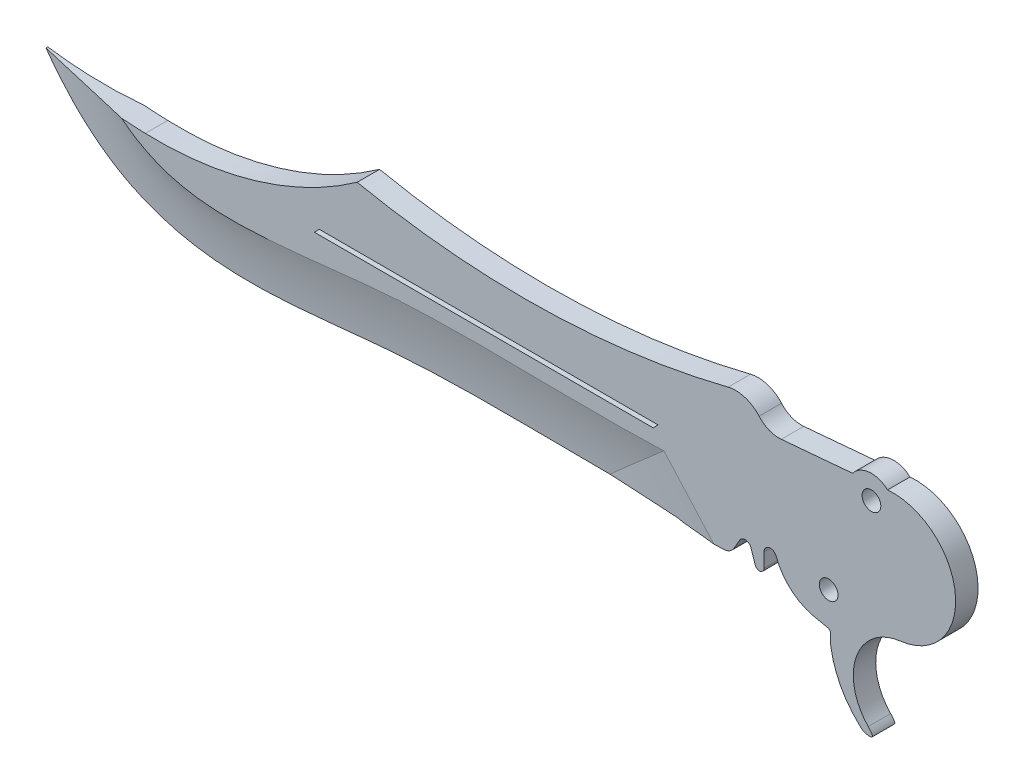
from build123d import *

# Parameters (mm, degrees)
SKETCH1_R           = 1.5
EXTRUDE1_DEPTH      = 1.8
SKETCH2_R           = 3.8
SKETCH2_R_2         = 1.5
EXTRUDE2_DEPTH      = 3.6
EXTRUDE4_DEPTH      = 1.0000001
EXTRUDE4_DEPTH_BACK = 4.6000001
EXTRUDE5_DEPTH      = 1.8
EXTRUDE6_DEPTH      = 15.6


with BuildPart() as part:
    # Sketch1 → Extrude1 (new body, symmetric)
    with BuildSketch(Plane.XY):
        with BuildLine():
            Line((0, 0), (85, -2.968265407))
            add(Edge.make_bspline(
                [(85, -2.968265407), (90.432696575, -3.157979352), (90.320000274, -9.186485994), (84.864174569, -11.468265407)],
                knots=[0, 0, 0, 0, 1, 1, 1, 1], degree=3))
            add(Edge.make_bspline(
                [(84.864174569, -11.468265407), (85.412432172, -11.551100755), (85.65372179, -11.5816869), (86.240355976, -11.568265407)],
                knots=[0, 0, 0, 0, 1, 1, 1, 1], degree=3))
            Line((86.240355976, -11.568265407), (92.79739008, -11.418248259))
            ThreePointArc((92.79739008, -11.418248259), (93.771255184, -11.13935102), (94.483539935, -10.419040433))
            Line((94.483539935, -10.419040433), (95.399690974, -8.832789171))
            ThreePointArc((95.399690974, -8.832789171), (96.365720198, -8.337944395), (97.213845062, -9.015268563))
            Line((97.213845062, -9.015268563), (97.890053812, -11.033764302))
            ThreePointArc((97.890053812, -11.033764302), (98.690727497, -11.516935392), (99.296449606, -10.804451443))
            Line((99.296449606, -10.804451443), (99.296449606, -8.512458344))
            ThreePointArc((99.296449606, -8.512458344), (100.130988793, -7.517233012), (101.25643455, -8.165539238))
            ThreePointArc((101.25643455, -8.165539238), (103.662770643, -11.648698906), (107.460240356, -13.520083004))
            add(Edge.make_bspline(
                [(109.981594087, -16.068548065), (109.883956183, -15.376284165), (110.125438788, -13.827677502), (109.603856517, -13.962844107), (107.460240356, -13.520083004)],
                knots=[0, 0, 0, 0, 0.378864353, 1, 1, 1, 1], degree=3))
            ThreePointArc((109.981594087, -16.068548065), (111.572311401, -20.981655948), (114.734992317, -25.064113549))
            add(Edge.make_bspline(
                [(116.01982802, -24.435412591), (117.243494627, -25.707343798), (115.658874629, -25.724857313), (115.189717461, -25.478212072), (114.734992317, -25.064113549)],
                knots=[0, 0, 0, 0, 0.466395795, 1, 1, 1, 1], degree=3))
            ThreePointArc((116.01982802, -24.435412591), (114.124431449, -15.605252946), (121.186493755, -9.975730453))
            ThreePointArc((121.186493755, -9.975730453), (129.992981594, 1.031156805), (119.124429723, 10.007814057))
            ThreePointArc((119.124429723, 10.007814057), (116.872428471, 3.435320035), (113.513338568, 9.516907191))
            Line((113.513338568, 9.516907191), (102.07679693, 8.516339447))
            ThreePointArc((102.07679693, 8.516339447), (100.123018101, 8.80612721), (98.511222742, 9.947768299))
            ThreePointArc((98.511222742, 9.947768299), (96.240661997, 11.424140555), (93.533381724, 11.5))
            ThreePointArc((93.533381724, 11.5), (63.839932849, 7.495889852), (34, 10.2))
            ThreePointArc((34, 10.2), (17.839693072, 2.301023093), (0, 0))
        make_face()
        with Locations((109.671236648, -8.589140112)):
            Circle(SKETCH1_R, mode=Mode.SUBTRACT)
    extrude(amount=EXTRUDE1_DEPTH, both=True)

    # Sketch2 → Extrude2 (add)
    with BuildSketch(Plane(origin=(0, 0, -1.8), x_dir=(-1, 0, 0), z_dir=(0, 0, -1))):
        with Locations((-116.541236648, 7.220859888)):
            Circle(SKETCH2_R)
        with Locations((-116.541236648, 7.220859888)):
            Circle(SKETCH2_R_2, mode=Mode.SUBTRACT)
    extrude(amount=-EXTRUDE2_DEPTH)

    # Sketch4 → Extrude4 (cut, two sides)
    with BuildSketch(Plane.XY.offset(1.8)) as extrude4_sk:
        Polygon((27.92344325, 0.625867146), (82.30194408, 0.625867146), (81.50194408, -0.174132854), (27.12344325, -0.174132854), align=None)
    extrude(amount=EXTRUDE4_DEPTH, mode=Mode.SUBTRACT)
    extrude(extrude4_sk.sketch, amount=-EXTRUDE4_DEPTH_BACK, mode=Mode.SUBTRACT)

    # Sketch3 → Extrude5 (add, symmetric)
    with BuildSketch(Plane.XY):
        with BuildLine():
            Line((0, 0), (85, -2.968265407))
            add(Edge.make_bspline(
                [(85, -2.968265407), (90.432696575, -3.157979352), (90.320000274, -9.186485994), (84.864174569, -11.468265407)],
                knots=[0, 0, 0, 0, 1, 1, 1, 1], degree=3))
            add(Edge.make_bspline(
                [(-17.585100414, 2.250690296), (-2.271498457, -19.245699758), (34.266177478, -9.425066518), (69.356930691, -12.273831268), (84.864174569, -11.468265407)],
                knots=[0, 0, 0, 0, 0.565859135, 1, 1, 1, 1], degree=3))
            ThreePointArc((-17.585100414, 2.250690296), (-8.844572437, 0.7188849), (0, 0))
        make_face()
    extrude(amount=EXTRUDE5_DEPTH, both=True)

    # Cut-Sweep7: sweep along a path in Sketch15
    with BuildLine(Plane.XY) as cut_sweep7_path:
        add(Edge.make_bspline(
            [(-13.512766022, 5.151740554), (-11.983742322, 3.005381393), (-10.425113419, 1.198004141), (-7.265046203, -1.860643744), (-5.663838935, -3.112993732), (-2.399704856, -5.188401658), (-0.735581292, -6.012268248), (2.696791194, -7.327345706), (4.466034028, -7.817924163), (8.134070773, -8.528500956), (10.032654139, -8.747694277), (13.954837882, -8.970147562), (15.977919689, -8.973189481), (20.129209175, -8.827360089), (22.257124308, -8.67855395), (26.596323983, -8.303333169), (28.807514729, -8.076988154), (33.295163059, -7.628402122), (35.571638535, -7.406157657), (39.025122457, -7.141820738), (40.176615027, -7.066378666), (42.46884108, -6.938598929), (43.611400574, -6.886048545), (49.307130803, -6.67110823), (53.808857048, -6.651747843), (62.725446441, -6.696699955), (67.140413174, -6.76098392), (73.875140907, -6.762401349), (76.216294179, -6.744715612), (78.551146627, -6.693496914)],
            knots=[0, 0, 0, 0, 0.0625, 0.0625, 0.125, 0.125, 0.1875, 0.1875, 0.25, 0.25, 0.3125, 0.3125, 0.375, 0.375, 0.4375, 0.4375, 0.5, 0.5, 0.5625, 0.5625, 0.59375, 0.59375, 0.625, 0.625, 0.75, 0.75, 0.875, 0.875, 0.941986542, 0.941986542, 0.941986542, 0.941986542], degree=3))
    # Sketch14 → Cut-Sweep7 (sweep, cut)
    with BuildSketch(Plane(origin=(0, 0, 0), x_dir=(-0.991908747, 0.126952894, 0), z_dir=(-0.126952894, -0.991908747, 0))):
        with BuildLine():
            Line((19.728546567, 1.8), (19.728546567, 0.025))
            ThreePointArc((19.728546567, 0.025), (11.967314183, 0.681060436), (4.259193941, 1.8))
            Line((4.259193941, 1.8), (19.728546567, 1.8))
        make_face()
        with BuildLine():
            Line((19.728546567, -0.025), (19.728546567, -1.8))
            Line((19.728546567, -1.8), (4.259193941, -1.8))
            ThreePointArc((4.259193941, -1.8), (11.967314183, -0.681060436), (19.728546567, -0.025))
        make_face()
    sweep(path=cut_sweep7_path.line, mode=Mode.SUBTRACT)

    # Sketch19 → Extrude6 (cut)
    with BuildSketch(Plane(origin=(38.204992999, -42.750114344, 0), x_dir=(0.745632155, 0.666357779, 0), z_dir=(-0.666357779, 0.745632155, 0))):
        with BuildLine():
            Line((46.50657917, -1.8), (60.395274478, -1.8))
            ThreePointArc((60.395274478, -1.8), (53.473495612, -0.773710727), (46.50657917, -0.120742414))
            Line((46.50657917, -0.120742414), (46.50657917, -1.8))
        make_face()
        with BuildLine():
            Line((46.50657917, 1.8), (46.50657917, 0.120742414))
            ThreePointArc((46.50657917, 0.120742414), (53.473495612, 0.773710727), (60.395274478, 1.8))
            Line((60.395274478, 1.8), (46.50657917, 1.8))
        make_face()
    extrude(amount=-EXTRUDE6_DEPTH, mode=Mode.SUBTRACT)


solid = part.part
